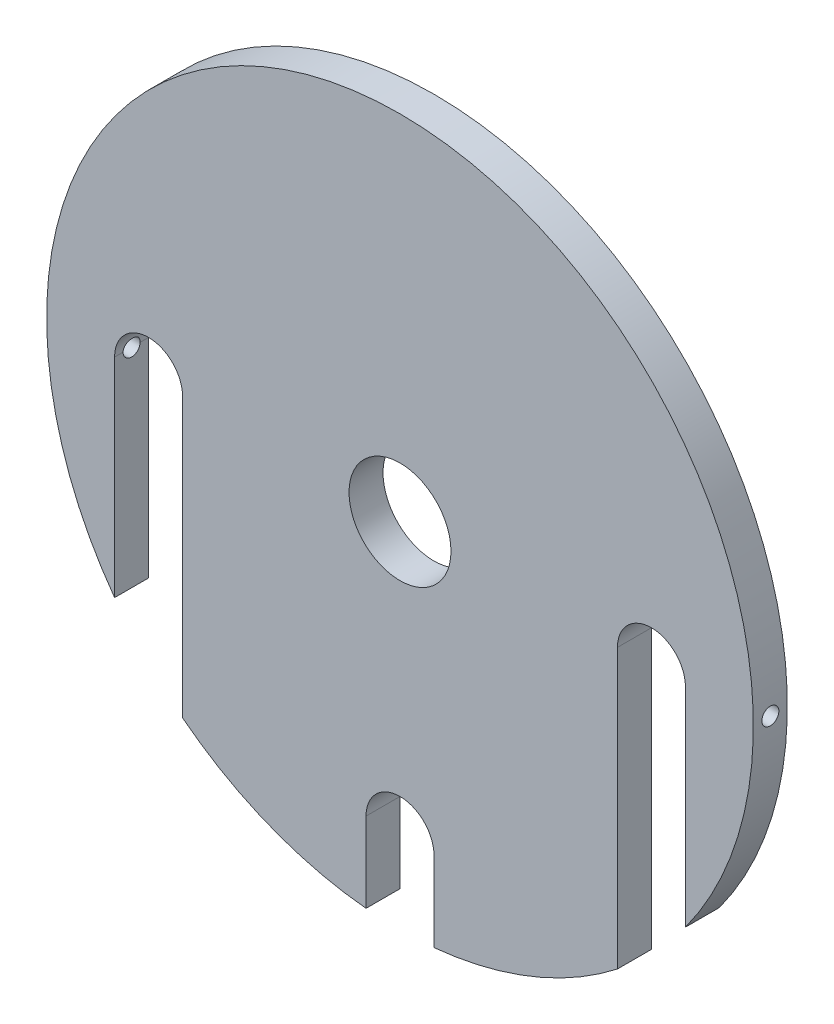
from build123d import *

# Parameters (mm, degrees)
SKETCH1_R              = 52
BOSS_EXTRUDE1_DEPTH    = 5
CUT_EXTRUDE1_DEPTH     = 10
SKETCH3_R              = 7.5
CUT_EXTRUDE2_DEPTH     = 10
M3_TAPPED_HOLE3_REACH  = 118.383
M3_TAPPED_HOLE3_BORE_R = 1.25


with BuildPart() as part:
    # Sketch1 → Boss-Extrude1 (new body)
    with BuildSketch(Plane.XY):
        Circle(SKETCH1_R)
    extrude(amount=BOSS_EXTRUDE1_DEPTH)

    # Sketch2 → Cut-Extrude1 (cut)
    with BuildSketch(Plane.XY.offset(5)):
        with BuildLine():
            Line((32, 0), (32, -45))
            Line((32, -45), (42, -45))
            Line((42, -45), (42, 3.54e-07))
            ThreePointArc((42, 3.54e-07), (36.999999823, 5), (32, 0))
        make_face()
        with BuildLine():
            Line((-5, -39.999999646), (-5, -55))
            Line((-5, -55), (5, -55))
            Line((5, -55), (5, -40))
            ThreePointArc((5, -40), (1.77e-07, -35), (-5, -39.999999646))
        make_face()
        with BuildLine():
            Line((-32, -45), (-42, -45))
            Line((-42, -45), (-42, 3.54e-07))
            ThreePointArc((-42, 3.54e-07), (-36.999999823, 5), (-32, 0))
            Line((-32, 0), (-32, -45))
        make_face()
    extrude(amount=-CUT_EXTRUDE1_DEPTH, mode=Mode.SUBTRACT)

    # Sketch3 → Cut-Extrude2 (cut)
    with BuildSketch(Plane.XY.offset(5)):
        Circle(SKETCH3_R)
    extrude(amount=-CUT_EXTRUDE2_DEPTH, mode=Mode.SUBTRACT)

    # M3 Tapped Hole3 bore → M3 Tapped Hole3 (cut, up to next)
    with BuildSketch(Plane(origin=(52, 0, 0), x_dir=(0, 0, -1), z_dir=(1, 0, 0)), mode=Mode.PRIVATE) as m3_tapped_hole3_sk1:
        with Locations((-2.5, 1.82e-07)):
            Circle(M3_TAPPED_HOLE3_BORE_R)
    m3_tapped_hole3_tool1 = extrude(m3_tapped_hole3_sk1.sketch, amount=-M3_TAPPED_HOLE3_REACH, mode=Mode.PRIVATE) & part.part
    m3_tapped_hole3 = m3_tapped_hole3_tool1.solids().sort_by_distance((52, 0, 2.5))[0]
    add(m3_tapped_hole3, mode=Mode.SUBTRACT)

    # Mirror1: M3 Tapped Hole3 across plane
    add(m3_tapped_hole3.mirror(Plane(origin=(0, 0, 0), x_dir=(0, 0, 1), z_dir=(1, 0, 0))), mode=Mode.SUBTRACT)


solid = part.part
